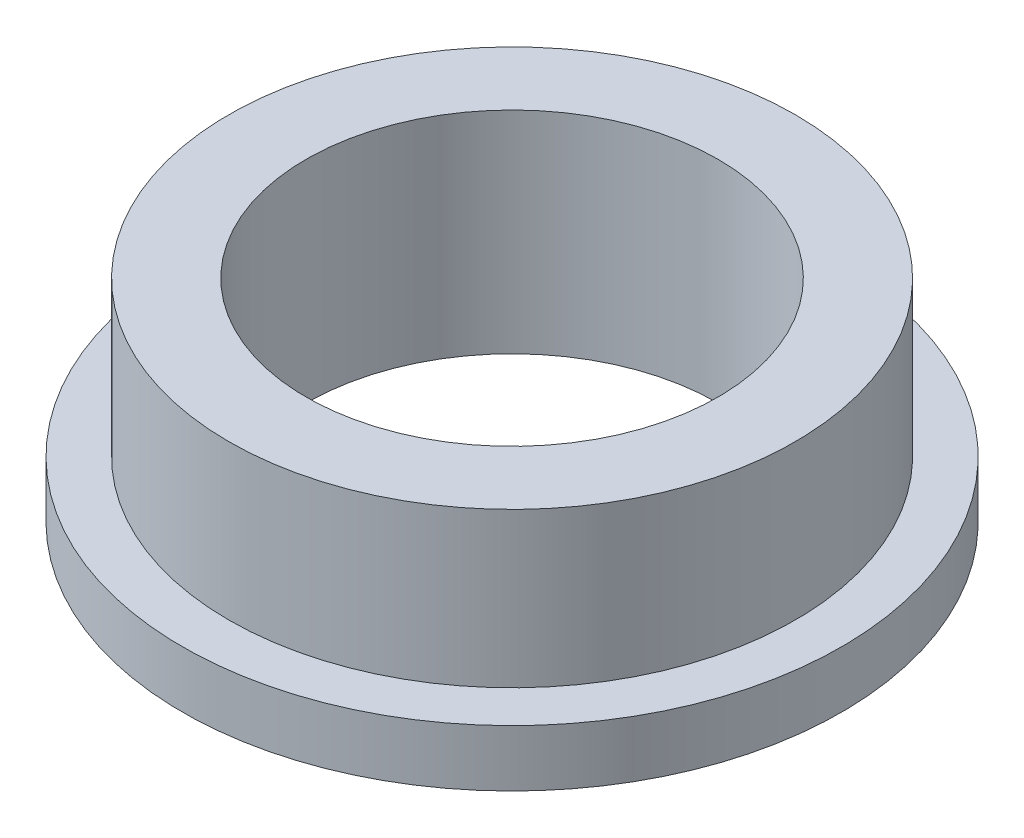
from build123d import *


with BuildPart() as part:
    # Sketch1 → Revolve1 (revolve)
    with BuildSketch(Plane.XY):
        Polygon((-6.4, 0), (-4, 0), (-4, 4.1), (-5.5, 4.1), (-5.5, 1.1), (-6.4, 1.1), align=None)
    revolve(axis=Axis((0, 0, 0), (0, 1, 0)))


solid = part.part
